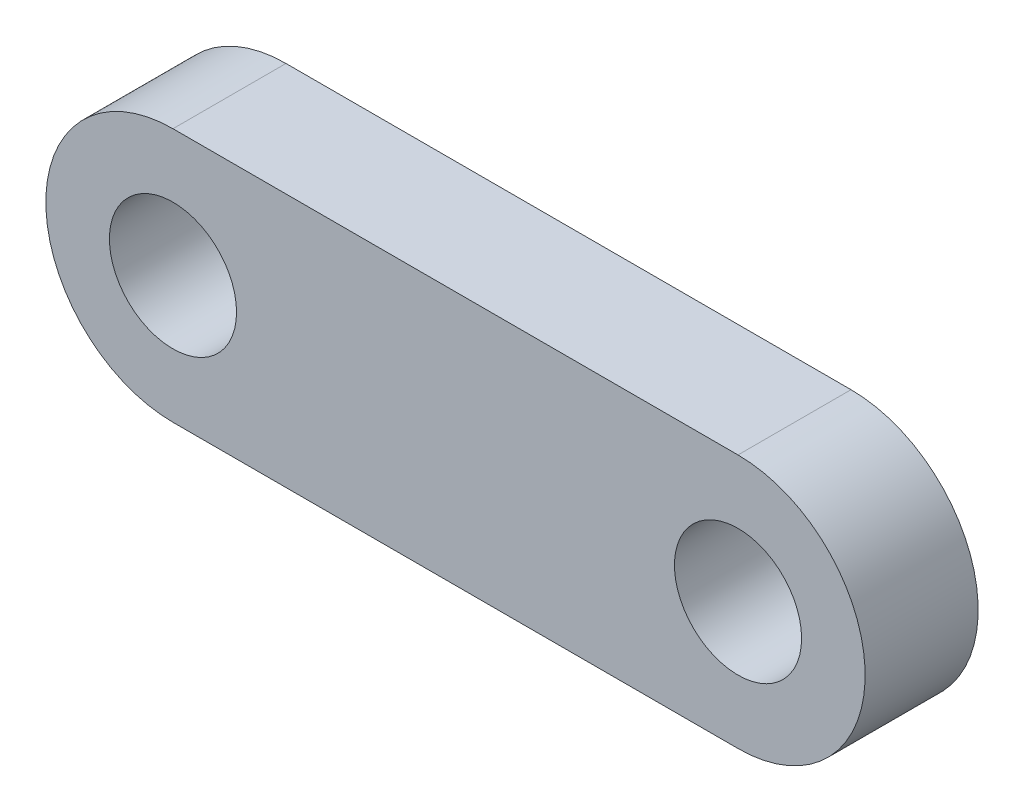
from build123d import *

# Parameters (mm, degrees)
SKETCH1_R           = 4.5
SKETCH1_R_2         = 2.25
BOSS_EXTRUDE1_DEPTH = 4


with BuildPart() as part:
    # Sketch1 → Boss-Extrude1 (new body)
    with BuildSketch(Plane.XY):
        with Locations((-10, 0)):
            Circle(SKETCH1_R)
        with Locations((-10, 0)):
            Circle(SKETCH1_R_2, mode=Mode.SUBTRACT)
        with BuildLine():
            Line((10, 4.5), (-10, 4.5))
            ThreePointArc((-10, 4.5), (-6.818019485, 3.181980515), (-5.5, 0))
            ThreePointArc((-5.5, 0), (-6.818019485, -3.181980515), (-10, -4.5))
            Line((-10, -4.5), (10, -4.5))
            ThreePointArc((10, -4.5), (5.5, 0), (10, 4.5))
        make_face()
        with Locations((10, 0)):
            Circle(SKETCH1_R)
        with Locations((10, 0)):
            Circle(SKETCH1_R_2, mode=Mode.SUBTRACT)
    extrude(amount=BOSS_EXTRUDE1_DEPTH)


solid = part.part
